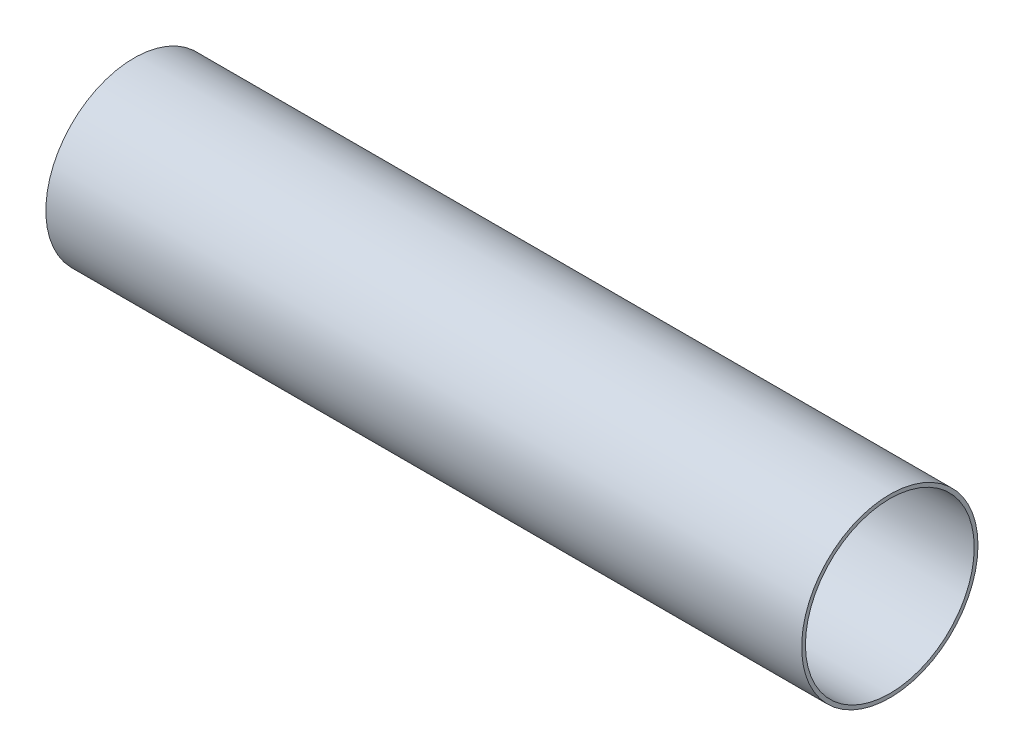
from build123d import *

# Parameters (mm, degrees)
SKETCH_1_R      = 35
SKETCH_1_R_2    = 33.5
EXTRUDE_1_DEPTH = 300


with BuildPart() as part:
    # 草图1 → 凸台-拉伸1 (new body)
    with BuildSketch(Plane(origin=(0, 0, 0), x_dir=(0, 0, -1), z_dir=(1, 0, 0))):
        Circle(SKETCH_1_R)
        Circle(SKETCH_1_R_2, mode=Mode.SUBTRACT)
    extrude(amount=EXTRUDE_1_DEPTH)


solid = part.part
